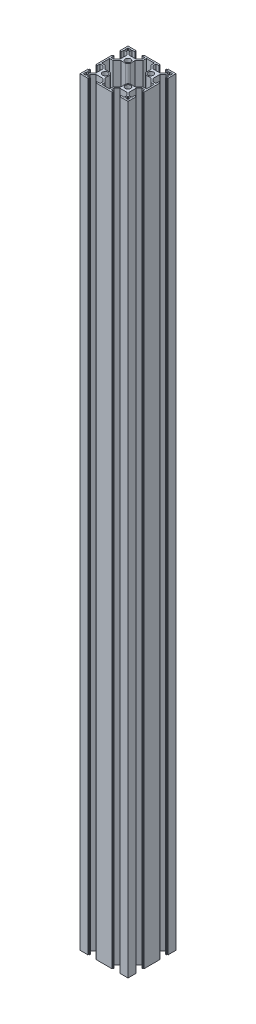
from build123d import *

# Parameters (mm, degrees)
SKETCH1_W                = 60
SKETCH1_H                = 60
BOSS_EXTRUDE1_DEPTH      = 950
CUT_EXTRUDE1_DEPTH       = 951.946896519
CIRPATTERN1_COUNT        = 4
CIRPATTERN1_COPY_1_DEPTH = 951.946896519
CIRPATTERN1_COPY_2_DEPTH = 951.946896519
CIRPATTERN1_COPY_3_DEPTH = 951.946896519
SKETCH4_R                = 3.4
CUT_EXTRUDE2_DEPTH       = 1000
FILLET1_R                = 0.2
FILLET2_R                = 0.2
FILLET3_R                = 0.2
FILLET4_R                = 0.2


with BuildPart() as part:
    # Sketch1 → Boss-Extrude1 (new body)
    with BuildSketch(Plane(origin=(0, 0, 0), x_dir=(1, 0, 0), z_dir=(0, 1, 0))):
        Rectangle(SKETCH1_W, SKETCH1_H)
        Polygon((-23.05, -28), (-6.95, -28), (-6.95, -24.4), (-10.615, -20.8), (-19.385, -20.8), (-23.05, -24.4), align=None, mode=Mode.SUBTRACT)
        Polygon((10.615, -20.8), (19.385, -20.8), (23.05, -24.4), (23.05, -28), (6.95, -28), (6.95, -24.4), align=None, mode=Mode.SUBTRACT)
        Polygon((19.385, 20.8), (23.05, 24.4), (23.05, 28), (6.95, 28), (6.95, 24.4), (10.615, 20.8), align=None, mode=Mode.SUBTRACT)
        Polygon((-23.05, 24.4), (-23.05, 28), (-6.95, 28), (-6.95, 24.4), (-10.615, 20.8), (-19.385, 20.8), align=None, mode=Mode.SUBTRACT)
        Polygon((-20.8, 19.385), (-24.4, 23.05), (-28, 23.05), (-28, 6.95), (-24.4, 6.95), (-20.8, 10.615), align=None, mode=Mode.SUBTRACT)
        Polygon((-24.4, -23.05), (-28, -23.05), (-28, -6.95), (-24.4, -6.95), (-20.8, -10.615), (-20.8, -19.385), align=None, mode=Mode.SUBTRACT)
        Polygon((20.8, -19.385), (24.4, -23.05), (28, -23.05), (28, -6.95), (24.4, -6.95), (20.8, -10.615), align=None, mode=Mode.SUBTRACT)
        Polygon((24.4, 23.05), (28, 23.05), (28, 6.95), (24.4, 6.95), (20.8, 10.615), (20.8, 19.385), align=None, mode=Mode.SUBTRACT)
    extrude(amount=BOSS_EXTRUDE1_DEPTH)

    # Sketch2 → Cut-Extrude1 (cut, through all)
    with BuildSketch(Plane(origin=(0, 950, 0), x_dir=(1, 0, 0), z_dir=(0, 1, 0))):
        Polygon((-19.1, -28), (-19.1, -29), (-20.1, -29), (-20.1, -30), (-9.9, -30), (-9.9, -29), (-10.9, -29), (-10.9, -28), align=None)
    cut_extrude1 = extrude(amount=-CUT_EXTRUDE1_DEPTH, mode=Mode.SUBTRACT)

    # Mirror1: Cut-Extrude1 across plane
    add(cut_extrude1.mirror(Plane(origin=(0, 0, 0), x_dir=(0, 0, 1), z_dir=(1, 0, 0))), mode=Mode.SUBTRACT)

    # CirPattern1: Cut-Extrude1 ×4 about axis
    cirpattern1_axis = Axis((0, 1050, 0), (0, -1, 0))
    for i in range(1, CIRPATTERN1_COUNT):
        add(cut_extrude1.rotate(cirpattern1_axis, i * 360 / CIRPATTERN1_COUNT), mode=Mode.SUBTRACT)

    # CirPattern1 copy 1 sketch → CirPattern1 copy 1 (cut, through all)
    with BuildSketch(Plane(origin=(0, 950, 0), x_dir=(0, 0, -1), z_dir=(0, 1, 0))):
        Polygon((-19.1, 28), (-19.1, 29), (-20.1, 29), (-20.1, 30), (-9.9, 30), (-9.9, 29), (-10.9, 29), (-10.9, 28), align=None)
    extrude(amount=-CIRPATTERN1_COPY_1_DEPTH, mode=Mode.SUBTRACT)

    # CirPattern1 copy 2 sketch → CirPattern1 copy 2 (cut, through all)
    with BuildSketch(Plane(origin=(0, 950, 0), x_dir=(1, 0, 0), z_dir=(0, 1, 0))):
        Polygon((-19.1, 28), (-19.1, 29), (-20.1, 29), (-20.1, 30), (-9.9, 30), (-9.9, 29), (-10.9, 29), (-10.9, 28), align=None)
    extrude(amount=-CIRPATTERN1_COPY_2_DEPTH, mode=Mode.SUBTRACT)

    # CirPattern1 copy 3 sketch → CirPattern1 copy 3 (cut, through all)
    with BuildSketch(Plane.ZX.offset(950)):
        Polygon((-19.1, 28), (-19.1, 29), (-20.1, 29), (-20.1, 30), (-9.9, 30), (-9.9, 29), (-10.9, 29), (-10.9, 28), align=None)
    extrude(amount=-CIRPATTERN1_COPY_3_DEPTH, mode=Mode.SUBTRACT)

    # Sketch4 → Cut-Extrude2 (cut)
    with BuildSketch(Plane(origin=(0, 950, 0), x_dir=(1, 0, 0), z_dir=(0, 1, 0))):
        with BuildLine():
            Line((-13.197035349, 9.797035349), (-18.8, 9.797035349))
            Line((-18.8, 9.797035349), (-23.561071557, 4.95))
            Line((-23.561071557, 4.95), (-28, 4.95))
            Line((-28, 4.95), (-28, -4.95))
            Line((-28, -4.95), (-23.561071557, -4.95))
            Line((-23.561071557, -4.95), (-18.8, -9.797035349))
            Line((-18.8, -9.797035349), (-13.197035349, -9.797035349))
            ThreePointArc((-13.197035349, -9.797035349), (-10.792872293, -10.792872293), (-9.797035349, -13.197035349))
            Line((-9.797035349, -13.197035349), (-9.797035349, -18.8))
            Line((-9.797035349, -18.8), (-4.95, -23.561071557))
            Line((-4.95, -23.561071557), (-4.95, -28))
            Line((-4.95, -28), (4.95, -28))
            Line((4.95, -28), (4.95, -23.561071557))
            Line((4.95, -23.561071557), (9.797035349, -18.8))
            Line((9.797035349, -18.8), (9.797035349, -13.197035349))
            ThreePointArc((9.797035349, -13.197035349), (10.792872293, -10.792872293), (13.197035349, -9.797035349))
            Line((13.197035349, -9.797035349), (18.8, -9.797035349))
            Line((18.8, -9.797035349), (23.561071557, -4.95))
            Line((23.561071557, -4.95), (28, -4.95))
            Line((28, -4.95), (28, 4.95))
            Line((28, 4.95), (23.561071557, 4.95))
            Line((23.561071557, 4.95), (18.8, 9.797035349))
            Line((18.8, 9.797035349), (13.197035349, 9.797035349))
            ThreePointArc((13.197035349, 9.797035349), (10.792872293, 10.792872293), (9.797035349, 13.197035349))
            Line((9.797035349, 13.197035349), (9.797035349, 18.8))
            Line((9.797035349, 18.8), (4.95, 23.561071557))
            Line((4.95, 23.561071557), (4.95, 28))
            Line((4.95, 28), (-4.95, 28))
            Line((-4.95, 28), (-4.95, 23.561071557))
            Line((-4.95, 23.561071557), (-9.797035349, 18.8))
            Line((-9.797035349, 18.8), (-9.797035349, 13.197035349))
            ThreePointArc((-9.797035349, 13.197035349), (-10.792872293, 10.792872293), (-13.197035349, 9.797035349))
        make_face()
        with BuildLine():
            ThreePointArc((-28, -27.5), (-27.853553391, -27.853553391), (-27.5, -28))
            Line((-27.5, -28), (-24.9, -28))
            ThreePointArc((-24.9, -28), (-24.546446609, -27.853553391), (-24.4, -27.5))
            Line((-24.4, -27.5), (-24.4, -24.9))
            ThreePointArc((-24.4, -24.9), (-24.546446609, -24.546446609), (-24.9, -24.4))
            Line((-24.9, -24.4), (-27.5, -24.4))
            ThreePointArc((-27.5, -24.4), (-27.853553391, -24.546446609), (-28, -24.9))
            Line((-28, -24.9), (-28, -27.5))
        make_face()
        with BuildLine():
            ThreePointArc((24.4, -27.5), (24.546446609, -27.853553391), (24.9, -28))
            Line((24.9, -28), (27.5, -28))
            ThreePointArc((27.5, -28), (27.853553391, -27.853553391), (28, -27.5))
            Line((28, -27.5), (28, -24.9))
            ThreePointArc((28, -24.9), (27.853553391, -24.546446609), (27.5, -24.4))
            Line((27.5, -24.4), (24.9, -24.4))
            ThreePointArc((24.9, -24.4), (24.546446609, -24.546446609), (24.4, -24.9))
            Line((24.4, -24.9), (24.4, -27.5))
        make_face()
        with BuildLine():
            ThreePointArc((-27.5, 28), (-27.853553391, 27.853553391), (-28, 27.5))
            Line((-28, 27.5), (-28, 24.9))
            ThreePointArc((-28, 24.9), (-27.853553391, 24.546446609), (-27.5, 24.4))
            Line((-27.5, 24.4), (-24.9, 24.4))
            ThreePointArc((-24.9, 24.4), (-24.546446609, 24.546446609), (-24.4, 24.9))
            Line((-24.4, 24.9), (-24.4, 27.5))
            ThreePointArc((-24.4, 27.5), (-24.546446609, 27.853553391), (-24.9, 28))
            Line((-24.9, 28), (-27.5, 28))
        make_face()
        with BuildLine():
            ThreePointArc((28, 27.5), (27.853553391, 27.853553391), (27.5, 28))
            Line((27.5, 28), (24.9, 28))
            ThreePointArc((24.9, 28), (24.546446609, 27.853553391), (24.4, 27.5))
            Line((24.4, 27.5), (24.4, 24.9))
            ThreePointArc((24.4, 24.9), (24.546446609, 24.546446609), (24.9, 24.4))
            Line((24.9, 24.4), (27.5, 24.4))
            ThreePointArc((27.5, 24.4), (27.853553391, 24.546446609), (28, 24.9))
            Line((28, 24.9), (28, 27.5))
        make_face()
        with Locations((14.298517674, 14.298517674)):
            Circle(SKETCH4_R)
        with Locations((14.298517674, -14.298517674)):
            Circle(SKETCH4_R)
        with Locations((-14.298517674, -14.298517674)):
            Circle(SKETCH4_R)
        with Locations((-14.298517674, 14.298517674)):
            Circle(SKETCH4_R)
    extrude(amount=-CUT_EXTRUDE2_DEPTH, mode=Mode.SUBTRACT)

    # Fillet1
    fillet1_edges = [part.edges().sort_by_distance(p)[0] for p in [
        (28, 475, -19.1),
        (30, 475, -20.1),
        (29, 475, -20.1),
        (29, 475, -19.1),
        (28, 475, 10.9),
        (29, 475, 9.9),
        (28, 475, 19.1),
        (29, 475, 20.1),
        (30, 475, 20.1),
        (29, 475, 19.1),
        (29, 475, 10.9),
        (30, 475, 9.9),
        (30, 475, -9.9),
        (29, 475, -9.9),
        (29, 475, -10.9),
        (28, 475, -10.9),
    ]]
    fillet(fillet1_edges, radius=FILLET1_R)

    # Fillet2
    fillet2_edges = [part.edges().sort_by_distance(p)[0] for p in [
        (-20.1, 0, -29.5),
        (-20.1, 950, -29.5),
        (-20.1, 475, -29),
        (-19.6, 0, -29),
        (-19.1, 475, -29),
        (-19.6, 950, -29),
        (-9.9, 475, -30),
        (-10.9, 475, -28),
        (-10.9, 475, -29),
        (-9.9, 475, -29),
        (19.1, 475, -28),
        (19.1, 475, -29),
        (20.1, 475, -29),
        (20.1, 475, -30),
        (10.9, 475, -28),
        (10.9, 475, -29),
        (9.9, 475, -29),
        (9.9, 475, -30),
        (-19.1, 475, -28),
        (-20.1, 475, -30),
    ]]
    fillet(fillet2_edges, radius=FILLET2_R)

    # Fillet3
    fillet3_edges = [part.edges().sort_by_distance(p)[0] for p in [
        (-29, 475, 9.9),
        (-29, 475, -20.1),
        (-30, 475, -20.1),
        (-29, 475, -19.1),
        (-28, 475, -10.9),
        (-29, 475, -10.9),
        (-29, 475, -9.9),
        (-30, 475, -9.9),
        (-29, 475, 10.9),
        (-30, 475, 9.9),
        (-28, 475, 19.1),
        (-29, 475, 19.1),
        (-29, 475, 20.1),
        (-30, 475, 20.1),
    ]]
    fillet(fillet3_edges, radius=FILLET3_R)

    # Fillet4
    fillet4_edges = [part.edges().sort_by_distance(p)[0] for p in [
        (-19.1, 475, 28),
        (10.9, 475, 28),
        (19.1, 475, 28),
        (20.1, 475, 29),
        (-10.9, 475, 28),
        (-9.9, 475, 29),
        (9.9, 475, 29),
        (-20.1, 475, 29),
        (19.1, 475, 29),
        (20.1, 475, 30),
        (10.9, 475, 29),
        (9.9, 475, 30),
        (-9.9, 475, 30),
        (-10.9, 475, 29),
        (-19.1, 475, 29),
        (-20.1, 475, 30),
    ]]
    fillet(fillet4_edges, radius=FILLET4_R)


solid = part.part
